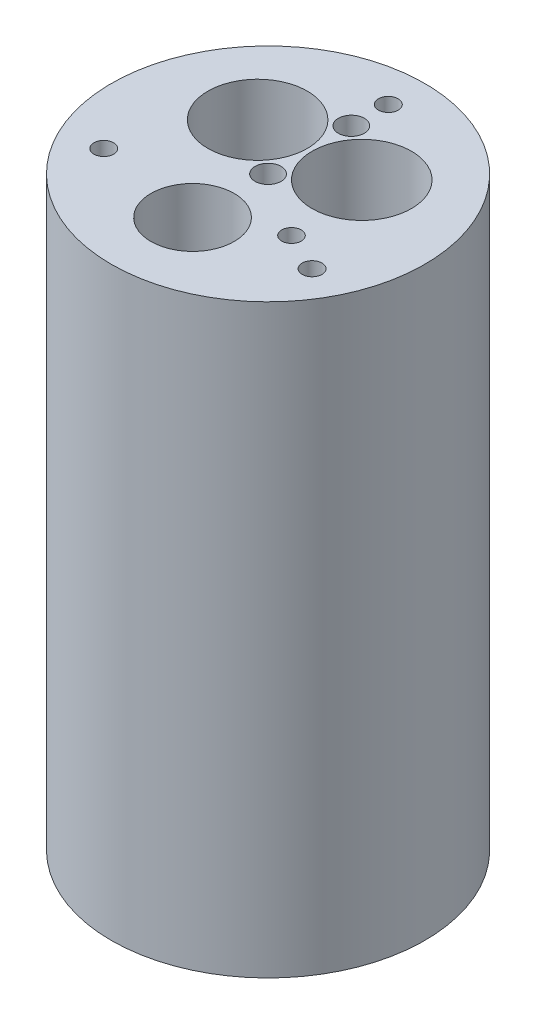
from build123d import *

# Parameters (mm, degrees)
SKETCH1_R               = 38.227
BOSS_EXTRUDE1_DEPTH     = 142.8496
SKETCH2_R               = 2.413
CUT_EXTRUDE1_DEPTH      = 153.737078924
SKETCH3_R               = 12.1285
CUT_EXTRUDE2_DEPTH      = 153.737078924
SKETCH4_R               = 3.175
CUT_EXTRUDE3_DEPTH      = 6.35
SKETCH5_R               = 10.16
CUT_EXTRUDE4_DEPTH      = 17.78
CUT_EXTRUDE5_DEPTH      = 153.737078924
CUT_EXTRUDE5_DEPTH_BACK = 153.737078924
SKETCH6_R               = 2.38125


with BuildPart() as part:
    # Sketch1 → Boss-Extrude1 (new body)
    with BuildSketch(Plane(origin=(0, 0, 0), x_dir=(1, 0, 0), z_dir=(0, 1, 0))):
        Circle(SKETCH1_R)
    extrude(amount=BOSS_EXTRUDE1_DEPTH)

    # Sketch2 → Cut-Extrude1 (cut, through all)
    with BuildSketch(Plane(origin=(0, 142.8496, 0), x_dir=(1, 0, 0), z_dir=(0, 1, 0))):
        with Locations((0, 29.337)):
            Circle(SKETCH2_R)
        with Locations((25.406587271, -14.6685)):
            Circle(SKETCH2_R)
        with Locations((-25.406587271, -14.6685)):
            Circle(SKETCH2_R)
    extrude(amount=-CUT_EXTRUDE1_DEPTH, mode=Mode.SUBTRACT)

    # Sketch3 → Cut-Extrude2 (cut, through all)
    with BuildSketch(Plane(origin=(0, 142.8496, 0), x_dir=(1, 0, 0), z_dir=(0, 1, 0))):
        with Locations((-12.7, 10.16)):
            Circle(SKETCH3_R)
        with Locations((12.7, 10.16)):
            Circle(SKETCH3_R)
    extrude(amount=-CUT_EXTRUDE2_DEPTH, mode=Mode.SUBTRACT)

    # Sketch4 → Cut-Extrude3 (cut)
    with BuildSketch(Plane(origin=(0, 142.8496, 0), x_dir=(1, 0, 0), z_dir=(0, 1, 0))):
        with Locations((0, 20.32)):
            Circle(SKETCH4_R)
        Circle(SKETCH4_R)
    extrude(amount=-CUT_EXTRUDE3_DEPTH, mode=Mode.SUBTRACT)

    # Sketch5 → Cut-Extrude4 (cut)
    with BuildSketch(Plane(origin=(0, 142.8496, 0), x_dir=(1, 0, 0), z_dir=(0, 1, 0))):
        with Locations((0, -18.415)):
            Circle(SKETCH5_R)
    extrude(amount=-CUT_EXTRUDE4_DEPTH, mode=Mode.SUBTRACT)

    # Sketch6 → Cut-Extrude5 (cut, two sides: drawn at the far end of the back side and taken through both)
    with BuildSketch(Plane(origin=(0, 142.8496, 0), x_dir=(1, 0, 0), z_dir=(0, 1, 0)).offset(-CUT_EXTRUDE5_DEPTH_BACK)):
        with Locations((15.875, -10.16)):
            Circle(SKETCH6_R)
    extrude(amount=CUT_EXTRUDE5_DEPTH + CUT_EXTRUDE5_DEPTH_BACK, mode=Mode.SUBTRACT)


solid = part.part
